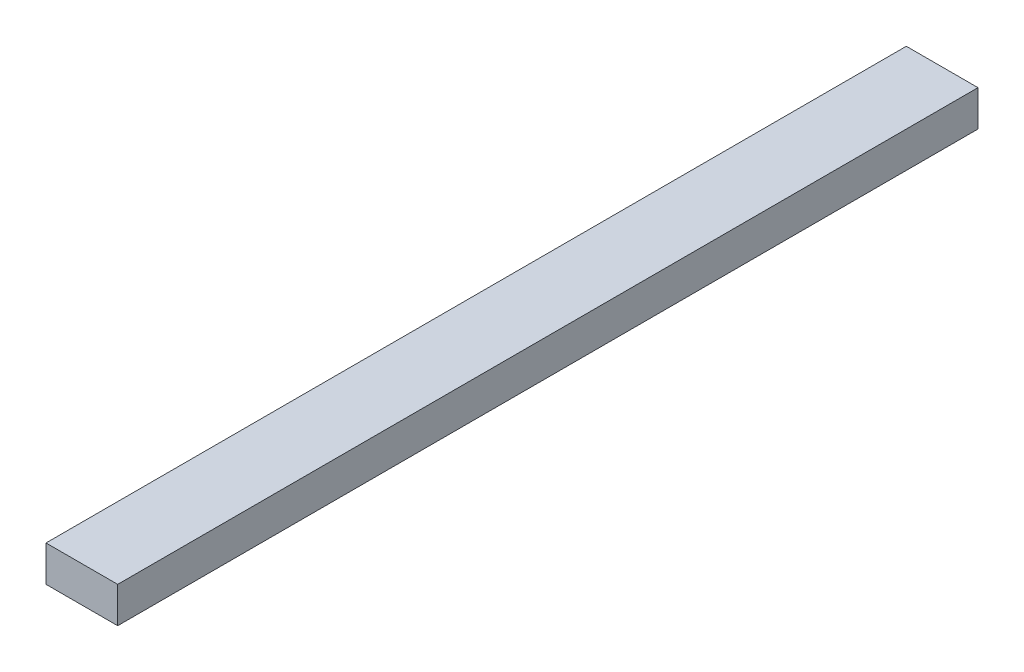
from build123d import *

# Parameters (mm, degrees)
SKETCH1_W           = 50.8
SKETCH1_H           = 25.4
BOSS_EXTRUDE1_DEPTH = 609.6


with BuildPart() as part:
    # Sketch1 → Boss-Extrude1 (new body)
    with BuildSketch(Plane.XY):
        with Locations((25.4, 12.7)):
            Rectangle(SKETCH1_W, SKETCH1_H)
    extrude(amount=BOSS_EXTRUDE1_DEPTH)


solid = part.part
